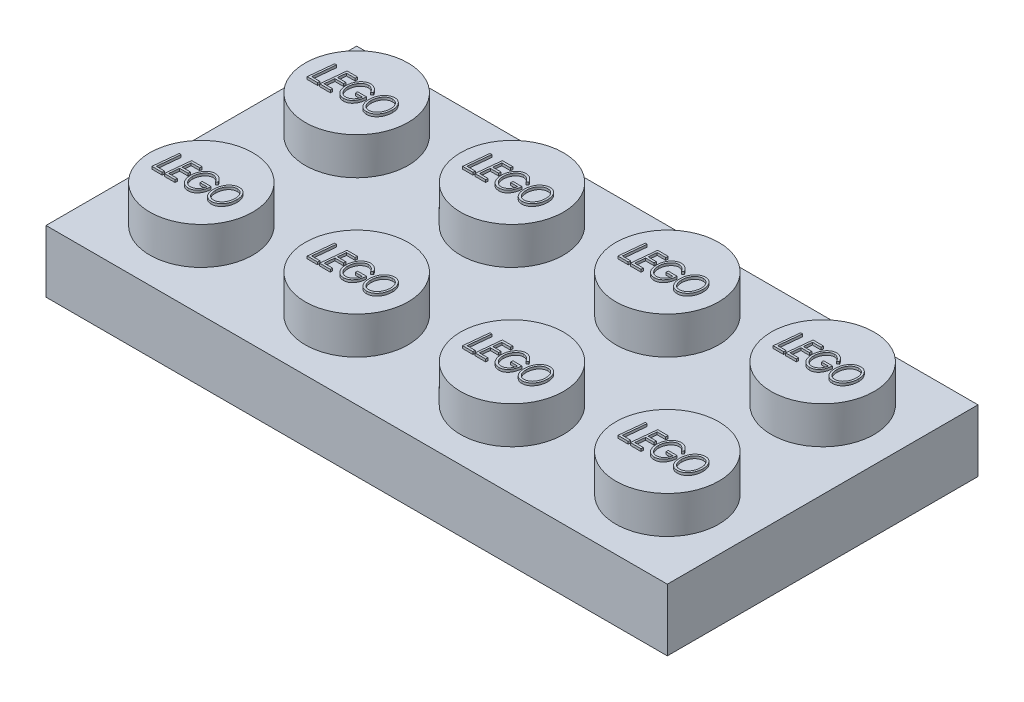
from build123d import *

# Parameters (mm, degrees)
SKETCH2_W            = 31.75
SKETCH2_H            = 15.875
BOSS_EXTRUDE3_DEPTH  = 3.175
SKETCH3_R            = 2.630752939
BOSS_EXTRUDE4_DEPTH  = 1.905
LPATTERN1_COUNT      = 4
LPATTERN1_PITCH      = 7.9375
LPATTERN1_COUNT_DIR2 = 2
LPATTERN1_PITCH_DIR2 = 7.9375
SHELL1_T             = -1.524
BOSS_EXTRUDE5_DEPTH  = 0.127
LPATTERN2_COUNT      = 4
LPATTERN2_PITCH      = 7.9375
LPATTERN2_COUNT_DIR2 = 2
LPATTERN2_PITCH_DIR2 = 7.9375
SKETCH5_R            = 3.175
SKETCH5_R_2          = 2.3876
BOSS_EXTRUDE6_DEPTH  = 1.651
LPATTERN3_COUNT      = 3
LPATTERN3_PITCH      = 7.9375


with BuildPart() as part:
    # Sketch2 → Boss-Extrude3 (new body)
    with BuildSketch(Plane(origin=(0, 0, 0), x_dir=(1, 0, 0), z_dir=(0, 1, 0))):
        with Locations((-17.733113381, 0.785891089)):
            Rectangle(SKETCH2_W, SKETCH2_H)
    extrude(amount=BOSS_EXTRUDE3_DEPTH)

    # Sketch3 → Boss-Extrude4 (add)
    with BuildSketch(Plane(origin=(0, 3.175, 0), x_dir=(1, 0, 0), z_dir=(0, 1, 0))):
        with Locations((-29.639363381, 4.754641089)):
            Circle(SKETCH3_R)
    boss_extrude4 = extrude(amount=BOSS_EXTRUDE4_DEPTH)

    # LPattern1: Boss-Extrude4 4 × 2
    with Locations(*[(i * LPATTERN1_PITCH, 0, j * LPATTERN1_PITCH_DIR2) for i in range(LPATTERN1_COUNT) for j in range(LPATTERN1_COUNT_DIR2) if (i, j) != (0, 0)]):
        add(boss_extrude4)

    # Shell1
    shell1_openings = [part.faces().sort_by_distance(p)[0] for p in [
        (-17.733113381, 0, -0.785891089),
    ]]
    offset(amount=SHELL1_T, openings=shell1_openings, kind=Kind.INTERSECTION)

    # Sketch4 → Boss-Extrude5 (add)
    with BuildSketch(Plane(origin=(0, 5.08, 0), x_dir=(1, 0, 0), z_dir=(0, 1, 0))):
        with BuildLine():
            add(Edge.make_bspline(
                [(-28.305252804, 5.379172513), (-28.288937242, 5.378720522), (-28.256787039, 5.377829863), (-28.209642348, 5.369659659), (-28.164574749, 5.356507424), (-28.12178341, 5.337650018), (-28.080999424, 5.313842859), (-28.042402029, 5.284550539), (-28.005976474, 5.250024202), (-27.972096941, 5.210647693), (-27.941240849, 5.167406166), (-27.914162228, 5.120902684), (-27.891287696, 5.071642915), (-27.872284528, 5.019696609), (-27.857815054, 4.964835989), (-27.847921704, 4.907187182), (-27.841197417, 4.84685662), (-27.840535196, 4.805673345), (-27.840196714, 4.784623234)],
                knots=[0, 0, 0, 0, 4.8912e-05, 9.6383e-05, 0.000143072, 0.00018944, 0.000236302, 0.000284436, 0.000334467, 0.000386593, 0.000440034, 0.000493616, 0.000547793, 0.000602762, 0.000659349, 0.000717739, 0.000778115, 0.000841241, 0.000841241, 0.000841241, 0.000841241], degree=3))
            add(Edge.make_bspline(
                [(-27.840196714, 4.784623234), (-27.840651912, 4.758992871), (-27.84154647, 4.708623908), (-27.849577078, 4.634691374), (-27.862846056, 4.563951657), (-27.880969306, 4.49615546), (-27.905195706, 4.431731122), (-27.93373939, 4.369990143), (-27.968435235, 4.311855249), (-28.007563625, 4.257287391), (-28.050312649, 4.207292778), (-28.096611554, 4.163785264), (-28.145418367, 4.12681072), (-28.196880083, 4.096525947), (-28.250949624, 4.072933007), (-28.307639153, 4.05602052), (-28.367048639, 4.045889546), (-28.407569869, 4.044665448), (-28.428131409, 4.044044308)],
                knots=[0, 0, 0, 0, 7.6873e-05, 0.000151071, 0.000222773, 0.000292635, 0.000361299, 0.000429016, 0.000496426, 0.000564063, 0.000630262, 0.000693435, 0.00075429, 0.000813586, 0.000872147, 0.000930825, 0.000990675, 0.00105233, 0.00105233, 0.00105233, 0.00105233], degree=3))
            add(Edge.make_bspline(
                [(-28.428131409, 4.044044308), (-28.445543391, 4.04451494), (-28.479609104, 4.04543571), (-28.529407151, 4.053188575), (-28.576379927, 4.066244037), (-28.620916198, 4.084066344), (-28.662597531, 4.107489433), (-28.70174584, 4.135865921), (-28.738049602, 4.169487075), (-28.771273919, 4.207966726), (-28.80112817, 4.250535984), (-28.827116893, 4.296615807), (-28.849406759, 4.345682347), (-28.867434916, 4.398084844), (-28.881360281, 4.453595942), (-28.891148203, 4.512216375), (-28.897451962, 4.573921358), (-28.898164991, 4.616189815), (-28.898530047, 4.637830365)],
                knots=[0, 0, 0, 0, 5.2215e-05, 0.000102157, 0.000150733, 0.000198212, 0.000245705, 0.000293794, 0.000342944, 0.000393802, 0.000446031, 0.000498666, 0.000552293, 0.000607486, 0.000664684, 0.000723782, 0.000785651, 0.000850556, 0.000850556, 0.000850556, 0.000850556], degree=3))
            add(Edge.make_bspline(
                [(-28.898530047, 4.637830365), (-28.898275755, 4.654713021), (-28.89777172, 4.68817633), (-28.894046232, 4.737832996), (-28.888441721, 4.786550271), (-28.87954345, 4.83402181), (-28.868993415, 4.8806248), (-28.855709602, 4.926031082), (-28.840231824, 4.970508016), (-28.822096109, 5.013561667), (-28.802304544, 5.055186009), (-28.779924961, 5.094446642), (-28.75620301, 5.131646309), (-28.730260179, 5.166341896), (-28.702939382, 5.199072462), (-28.673248581, 5.229081319), (-28.641916862, 5.256911788), (-28.608844542, 5.282323432), (-28.574507661, 5.305193307), (-28.53885684, 5.324828759), (-28.502381437, 5.341794401), (-28.464845537, 5.355489869), (-28.426263101, 5.365956739), (-28.386821371, 5.373598515), (-28.346326258, 5.378302894), (-28.319003201, 5.378881385), (-28.305252804, 5.379172513)],
                knots=[0, 0, 0, 0, 5.0643e-05, 0.00010038, 0.000149323, 0.000197677, 0.000245196, 0.000292617, 0.000339526, 0.000386395, 0.000432706, 0.000477705, 0.000521881, 0.000564978, 0.000607585, 0.000649681, 0.000691492, 0.000733218, 0.000774708, 0.000815134, 0.000855202, 0.000895282, 0.000934843, 0.000975008, 0.001015717, 0.001056959, 0.001056959, 0.001056959, 0.001056959], degree=3))
        make_face()
        with BuildLine():
            add(Edge.make_bspline(
                [(-28.306524839, 5.265198154), (-28.318240695, 5.264974538), (-28.341312052, 5.264534185), (-28.375455089, 5.260405022), (-28.408733333, 5.254641281), (-28.440930149, 5.2453884), (-28.472346349, 5.23449868), (-28.502468102, 5.220073421), (-28.532013851, 5.204049224), (-28.560252468, 5.185085614), (-28.587202565, 5.163901314), (-28.613032818, 5.1407675), (-28.637169877, 5.115240955), (-28.659841986, 5.087622005), (-28.681246132, 5.058107871), (-28.701185517, 5.02643651), (-28.719380866, 4.992497975), (-28.736363002, 4.956872571), (-28.751545612, 4.919838387), (-28.764850545, 4.882001808), (-28.775655738, 4.843441788), (-28.784922724, 4.804516904), (-28.792057451, 4.764939705), (-28.797096643, 4.724771762), (-28.800266171, 4.683929196), (-28.800646199, 4.656492627), (-28.80083774, 4.642664099)],
                knots=[0, 0, 0, 0, 3.5131e-05, 6.9182e-05, 0.000103064, 0.000136333, 0.000169567, 0.000202688, 0.000236393, 0.000270332, 0.000304582, 0.000339169, 0.000374259, 0.000409863, 0.000446299, 0.000483568, 0.000522044, 0.000561759, 0.000601917, 0.000642065, 0.000682008, 0.000721995, 0.000762067, 0.000802584, 0.000843403, 0.000884884, 0.000884884, 0.000884884, 0.000884884], degree=3))
            add(Edge.make_bspline(
                [(-28.80083774, 4.642664099), (-28.800235087, 4.619656102), (-28.799058702, 4.574744224), (-28.790356518, 4.509171597), (-28.775623002, 4.447271889), (-28.758322318, 4.398577377), (-28.741945478, 4.361918699), (-28.728546935, 4.336186177), (-28.713707036, 4.312362342), (-28.698173277, 4.289966829), (-28.681317345, 4.269317365), (-28.663316597, 4.250238819), (-28.644098252, 4.232904881), (-28.624000544, 4.216982903), (-28.602693952, 4.20305699), (-28.580432244, 4.191085763), (-28.557341115, 4.180768501), (-28.533261365, 4.172401088), (-28.5082118, 4.166087649), (-28.482369593, 4.161495703), (-28.455586358, 4.158635539), (-28.437381969, 4.158226513), (-28.428131409, 4.158018667)],
                knots=[0, 0, 0, 0, 6.9012e-05, 0.000134712, 0.000198022, 0.000259579, 0.000289414, 0.000318432, 0.000346532, 0.000373564, 0.000400145, 0.00042642, 0.000452175, 0.000477724, 0.000503267, 0.000528424, 0.00055348, 0.000579065, 0.000604796, 0.000630896, 0.000657755, 0.000685504, 0.000685504, 0.000685504, 0.000685504], degree=3))
            add(Edge.make_bspline(
                [(-28.428131409, 4.158018667), (-28.417091642, 4.158226379), (-28.395189649, 4.158638462), (-28.362743014, 4.163069526), (-28.330839875, 4.169171543), (-28.299680616, 4.178557501), (-28.268981622, 4.1901992), (-28.239080239, 4.204836709), (-28.209554369, 4.221656145), (-28.180981592, 4.241259996), (-28.153323246, 4.263059149), (-28.127029651, 4.2869402), (-28.102678523, 4.31313992), (-28.079270381, 4.340857537), (-28.057853581, 4.370957713), (-28.03748102, 4.402800133), (-28.019436597, 4.437043875), (-28.002289683, 4.472756352), (-27.987195804, 4.510002211), (-27.973831104, 4.548157353), (-27.963038994, 4.587233797), (-27.953808788, 4.626845971), (-27.946645602, 4.667266057), (-27.941634015, 4.708370092), (-27.938453376, 4.750312827), (-27.938078496, 4.778511748), (-27.937889022, 4.79276426)],
                knots=[0, 0, 0, 0, 3.3097e-05, 6.5662e-05, 9.8093e-05, 0.000130454, 0.000163149, 0.000196488, 0.000230221, 0.000265008, 0.000300331, 0.000335806, 0.000371442, 0.000407566, 0.000444563, 0.000482183, 0.000520883, 0.000560598, 0.000600991, 0.00064138, 0.000681813, 0.000722543, 0.000763366, 0.000804893, 0.000846727, 0.000889479, 0.000889479, 0.000889479, 0.000889479], degree=3))
            add(Edge.make_bspline(
                [(-27.937889022, 4.79276426), (-27.938310528, 4.811264), (-27.939134256, 4.847417056), (-27.944657078, 4.900202516), (-27.954311503, 4.949996074), (-27.967811434, 4.996843587), (-27.985074403, 5.040781654), (-28.006340365, 5.081809748), (-28.031438245, 5.119934561), (-28.051184805, 5.142857206), (-28.061022034, 5.15427668)],
                knots=[0, 0, 0, 0, 5.5498e-05, 0.000108457, 0.000158999, 0.000207469, 0.000254523, 0.000300379, 0.00034589, 0.00039107, 0.00039107, 0.00039107, 0.00039107], degree=3))
            add(Edge.make_bspline(
                [(-28.061022034, 5.15427668), (-28.069596423, 5.163096064), (-28.086448725, 5.180429887), (-28.114064478, 5.203115094), (-28.142916157, 5.222389045), (-28.173176726, 5.237947562), (-28.204661108, 5.250365639), (-28.237551414, 5.258916547), (-28.271672838, 5.264150728), (-28.29480339, 5.264845883), (-28.306524839, 5.265198154)],
                knots=[0, 0, 0, 0, 3.6878e-05, 7.2482e-05, 0.000106986, 0.00014078, 0.00017437, 0.000208309, 0.000242526, 0.000277679, 0.000277679, 0.000277679, 0.000277679], degree=3))
        make_face(mode=Mode.SUBTRACT)
        with BuildLine():
            Line((-29.093914663, 5.079226599), (-29.172780849, 5.004685333))
            add(Edge.make_bspline(
                [(-29.172780849, 5.004685333), (-29.178963448, 5.014919943), (-29.191142636, 5.03508124), (-29.210771002, 5.0639219), (-29.231332065, 5.090766309), (-29.252595821, 5.115943823), (-29.274608942, 5.139287343), (-29.297515126, 5.160749301), (-29.321377364, 5.180091456), (-29.345628971, 5.197942406), (-29.370585383, 5.213660022), (-29.395674881, 5.227481566), (-29.421105088, 5.238904833), (-29.446492296, 5.248734726), (-29.472209217, 5.256136896), (-29.498114876, 5.261089256), (-29.52401686, 5.264689825), (-29.541404411, 5.265029123), (-29.550066506, 5.265198154)],
                knots=[0, 0, 0, 0, 3.5867e-05, 7.0655e-05, 0.000104594, 0.000137266, 0.00016948, 0.0002008, 0.000231355, 0.000261581, 0.000291084, 0.000319773, 0.000347439, 0.000374655, 0.000401388, 0.000427582, 0.000453742, 0.000479711, 0.000479711, 0.000479711, 0.000479711], degree=3))
            add(Edge.make_bspline(
                [(-29.550066506, 5.265198154), (-29.559744117, 5.264942089), (-29.57917338, 5.264428001), (-29.608169712, 5.260605848), (-29.636763009, 5.253771652), (-29.665205226, 5.244988175), (-29.693199304, 5.233098144), (-29.720975808, 5.218900423), (-29.748300924, 5.20184576), (-29.775387954, 5.182752056), (-29.801353277, 5.16117013), (-29.826193668, 5.13792049), (-29.849525479, 5.112994152), (-29.871637607, 5.086452282), (-29.891799288, 5.057845897), (-29.911039341, 5.027830316), (-29.928514544, 4.995991744), (-29.944493446, 4.962671117), (-29.958942507, 4.928317995), (-29.971436065, 4.893155428), (-29.981869151, 4.857372561), (-29.99051622, 4.820944025), (-29.997426519, 4.783854091), (-30.002239772, 4.746142046), (-30.005070175, 4.707836031), (-30.005495178, 4.682101861), (-30.005709534, 4.669122433)],
                knots=[0, 0, 0, 0, 2.903e-05, 5.8283e-05, 8.7534e-05, 0.000117144, 0.000147477, 0.000178653, 0.000210636, 0.000244026, 0.000278, 0.000311837, 0.000346034, 0.000380367, 0.000415383, 0.000450953, 0.000487277, 0.000524259, 0.000561774, 0.000599029, 0.000636142, 0.000673537, 0.00071131, 0.000749271, 0.000787535, 0.000826472, 0.000826472, 0.000826472, 0.000826472], degree=3))
            add(Edge.make_bspline(
                [(-30.005709534, 4.669122433), (-30.005404517, 4.651721569), (-30.004804735, 4.617504752), (-29.998964578, 4.567164063), (-29.989898572, 4.518756671), (-29.977238082, 4.472223428), (-29.960573226, 4.42784351), (-29.940496756, 4.385349364), (-29.916336636, 4.345047805), (-29.889232363, 4.306998763), (-29.859436861, 4.272231716), (-29.827538791, 4.241833165), (-29.794168653, 4.215836332), (-29.758887547, 4.194859762), (-29.722244488, 4.177985595), (-29.683628118, 4.166780357), (-29.643731586, 4.159194772), (-29.616502684, 4.158413751), (-29.602728765, 4.158018667)],
                knots=[0, 0, 0, 0, 5.2184e-05, 0.000102614, 0.000151811, 0.000199829, 0.000247083, 0.000293853, 0.000340625, 0.000387856, 0.000433855, 0.000477763, 0.000519845, 0.000560465, 0.000600659, 0.0006405, 0.000680822, 0.0007221, 0.0007221, 0.0007221, 0.0007221], degree=3))
            add(Edge.make_bspline(
                [(-29.602728765, 4.158018667), (-29.58604699, 4.158598006), (-29.552692088, 4.159756384), (-29.5035101, 4.170959003), (-29.455126528, 4.187625511), (-29.408742246, 4.211693168), (-29.364902852, 4.24107788), (-29.324741699, 4.275137052), (-29.289370854, 4.314132031), (-29.257941621, 4.35741319), (-29.231399386, 4.406100752), (-29.207967949, 4.459501556), (-29.189368696, 4.518549092), (-29.180101865, 4.559989791), (-29.175324919, 4.581352)],
                knots=[0, 0, 0, 0, 4.9973e-05, 9.9921e-05, 0.000150611, 0.000203177, 0.000256167, 0.000308679, 0.000360721, 0.000413748, 0.000468753, 0.000526746, 0.000588456, 0.000654111, 0.000654111, 0.000654111, 0.000654111], degree=3))
            Line((-29.175324919, 4.581352), (-29.533530047, 4.581352))
            Line((-29.533530047, 4.581352), (-29.533530047, 4.695326359))
            Line((-29.533530047, 4.695326359), (-29.077632611, 4.695326359))
            add(Edge.make_bspline(
                [(-29.077632611, 4.695326359), (-29.079147348, 4.671630935), (-29.082111809, 4.625257073), (-29.092400622, 4.557663764), (-29.105809892, 4.493369383), (-29.123959261, 4.432650411), (-29.146119073, 4.37537214), (-29.172383696, 4.321477624), (-29.202684698, 4.270933421), (-29.236886358, 4.224225256), (-29.2743411, 4.182195788), (-29.314150719, 4.145176879), (-29.35636965, 4.113917018), (-29.400840886, 4.088167818), (-29.447862093, 4.06856876), (-29.496956365, 4.05415967), (-29.548411401, 4.045619356), (-29.583447035, 4.044574047), (-29.601202323, 4.044044308)],
                knots=[0, 0, 0, 0, 7.12e-05, 0.000139344, 0.00020491, 0.000268096, 0.00032923, 0.000388964, 0.000447735, 0.000505793, 0.000562373, 0.000616384, 0.000668589, 0.000719646, 0.000770156, 0.000821037, 0.000872858, 0.000926102, 0.000926102, 0.000926102, 0.000926102], degree=3))
            add(Edge.make_bspline(
                [(-29.601202323, 4.044044308), (-29.619385894, 4.044552296), (-29.655105516, 4.045550182), (-29.707299555, 4.054296421), (-29.75699617, 4.067841152), (-29.803992613, 4.087506656), (-29.848483506, 4.112374207), (-29.889911362, 4.143464588), (-29.92908117, 4.179412869), (-29.964953935, 4.220871562), (-29.997220455, 4.26652386), (-30.025935064, 4.315160597), (-30.049843162, 4.366865748), (-30.069483, 4.421262957), (-30.084754392, 4.478548833), (-30.095640615, 4.538607223), (-30.102022855, 4.601566492), (-30.102935624, 4.644430286), (-30.103401842, 4.666323955)],
                knots=[0, 0, 0, 0, 5.4515e-05, 0.000107089, 0.00015832, 0.000208732, 0.000259537, 0.000310826, 0.000363759, 0.000418756, 0.000474947, 0.000531277, 0.000587959, 0.00064558, 0.000704576, 0.000765604, 0.000828511, 0.000894188, 0.000894188, 0.000894188, 0.000894188], degree=3))
            add(Edge.make_bspline(
                [(-30.103401842, 4.666323955), (-30.103112688, 4.682101713), (-30.102538429, 4.713436248), (-30.099308693, 4.759994442), (-30.093359874, 4.805749539), (-30.085201431, 4.850644315), (-30.075087868, 4.894945835), (-30.062349417, 4.938327925), (-30.047279977, 4.98094547), (-30.030082896, 5.022494256), (-30.010796538, 5.062577802), (-29.989774967, 5.100800933), (-29.966713169, 5.136684011), (-29.942411305, 5.170754132), (-29.915866325, 5.202226268), (-29.887763574, 5.231556391), (-29.85824517, 5.259016319), (-29.826751574, 5.283795413), (-29.794050127, 5.306042524), (-29.760808143, 5.325834039), (-29.726670542, 5.34211596), (-29.692039862, 5.355771227), (-29.656574043, 5.366079712), (-29.620653252, 5.373904452), (-29.584008727, 5.378221983), (-29.559405145, 5.378854133), (-29.547013621, 5.379172513)],
                knots=[0, 0, 0, 0, 4.7337e-05, 9.4011e-05, 0.000139924, 0.000185684, 0.000230857, 0.000276183, 0.000321242, 0.000366409, 0.000411014, 0.000454628, 0.000497184, 0.000538913, 0.000580086, 0.000620572, 0.000660721, 0.00070093, 0.000740658, 0.000779316, 0.000816866, 0.000854, 0.000890868, 0.000927543, 0.000964179, 0.001001354, 0.001001354, 0.001001354, 0.001001354], degree=3))
            add(Edge.make_bspline(
                [(-29.547013621, 5.379172513), (-29.53581258, 5.378887615), (-29.513617508, 5.378323085), (-29.480686743, 5.375041802), (-29.448507377, 5.369229816), (-29.417154025, 5.36060081), (-29.386237016, 5.350370482), (-29.356163555, 5.337162127), (-29.326652709, 5.322040578), (-29.298051616, 5.304229546), (-29.269929478, 5.284471776), (-29.242858468, 5.261858803), (-29.215928721, 5.237508559), (-29.190097084, 5.210414835), (-29.16475823, 5.181124192), (-29.140569119, 5.149192743), (-29.116366049, 5.115396141), (-29.101497389, 5.091442492), (-29.093914663, 5.079226599)],
                knots=[0, 0, 0, 0, 3.3606e-05, 6.6591e-05, 9.9176e-05, 0.000131574, 0.000164077, 0.000196781, 0.000230006, 0.000263473, 0.000297779, 0.000333024, 0.000369219, 0.000406644, 0.000445248, 0.000485345, 0.000526779, 0.000569901, 0.000569901, 0.000569901, 0.000569901], degree=3))
        make_face()
        Polygon((-30.184812099, 5.34660841), (-30.198804486, 5.232634051), (-30.635621393, 5.232634051), (-30.678870592, 4.809300718), (-30.249940304, 4.809300718), (-30.262660656, 4.695326359), (-30.690573316, 4.695326359), (-30.741963541, 4.190582769), (-30.298786457, 4.190582769), (-30.310234775, 4.07660841), (-30.852376201, 4.07660841), (-30.722628605, 5.34660841), align=None)
        Polygon((-31.357883012, 5.34660841), (-31.259427483, 5.34660841), (-31.377217948, 4.190582769), (-30.950068509, 4.190582769), (-30.961262419, 4.07660841), (-31.487376201, 4.07660841), align=None)
    boss_extrude5 = extrude(amount=BOSS_EXTRUDE5_DEPTH)

    # LPattern2: Boss-Extrude5 4 × 2
    with Locations(*[(i * LPATTERN2_PITCH, 0, j * LPATTERN2_PITCH_DIR2) for i in range(LPATTERN2_COUNT) for j in range(LPATTERN2_COUNT_DIR2) if (i, j) != (0, 0)]):
        add(boss_extrude5)

    # Sketch5 → Boss-Extrude6 (add)
    with BuildSketch(Plane.XZ):
        with Locations((-9.795613381, -0.785891089)):
            Circle(SKETCH5_R)
        with Locations((-9.795613381, -0.785891089)):
            Circle(SKETCH5_R_2, mode=Mode.SUBTRACT)
    boss_extrude6 = extrude(amount=-BOSS_EXTRUDE6_DEPTH)

    # LPattern3: Boss-Extrude6 ×3
    with Locations(*[(-i * LPATTERN3_PITCH, 0, 0) for i in range(1, LPATTERN3_COUNT)]):
        add(boss_extrude6)


solid = part.part
